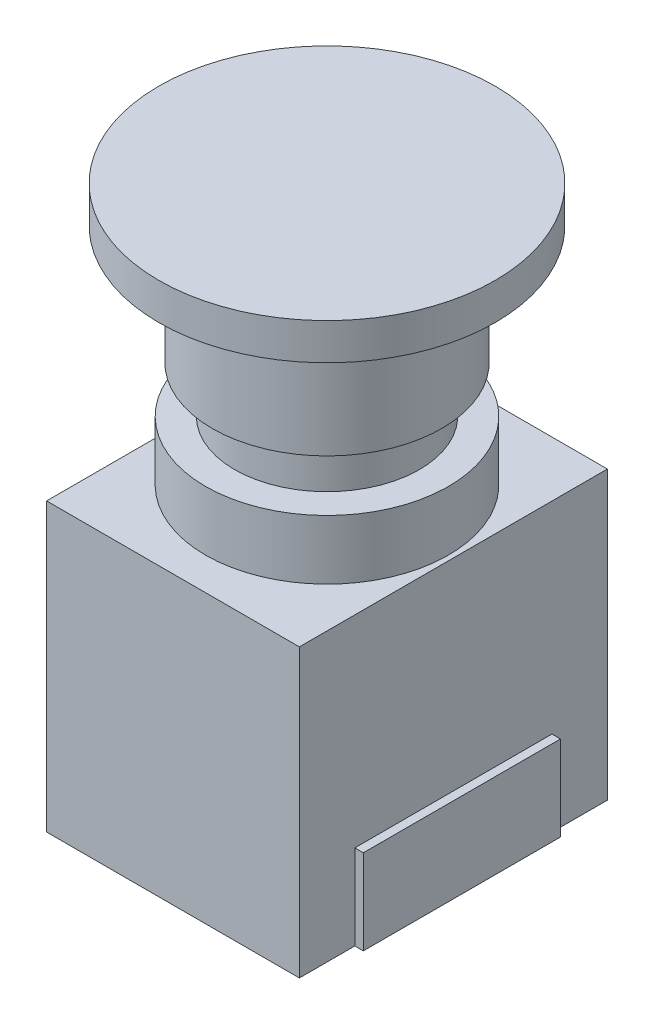
from build123d import *

# Parameters (mm, degrees)
SKETCH2_W           = 29.75
SKETCH2_H           = 36.25
BOSS_EXTRUDE1_DEPTH = 33.75
SKETCH3_R           = 14.3
BOSS_EXTRUDE2_DEPTH = 7
SKETCH4_R           = 10.875
BOSS_EXTRUDE3_DEPTH = 5.5
SKETCH5_R           = 13.5
BOSS_EXTRUDE4_DEPTH = 13.95
SKETCH6_R           = 19.8
BOSS_EXTRUDE5_DEPTH = 4.3
SKETCH7_W           = 23.2
SKETCH7_H           = 10
BOSS_EXTRUDE6_DEPTH = 1


with BuildPart() as part:
    # Sketch2 → Boss-Extrude1 (new body)
    with BuildSketch(Plane(origin=(0, 0, 0), x_dir=(1, 0, 0), z_dir=(0, 1, 0))):
        Rectangle(SKETCH2_W, SKETCH2_H)
    extrude(amount=BOSS_EXTRUDE1_DEPTH)

    # Sketch3 → Boss-Extrude2 (add)
    with BuildSketch(Plane(origin=(0, 33.75, 0), x_dir=(1, 0, 0), z_dir=(0, 1, 0))):
        Circle(SKETCH3_R)
    extrude(amount=BOSS_EXTRUDE2_DEPTH)

    # Sketch4 → Boss-Extrude3 (add)
    with BuildSketch(Plane(origin=(0, 40.75, 0), x_dir=(1, 0, 0), z_dir=(0, 1, 0))):
        Circle(SKETCH4_R)
    extrude(amount=BOSS_EXTRUDE3_DEPTH)

    # Sketch5 → Boss-Extrude4 (add)
    with BuildSketch(Plane(origin=(0, 46.25, 0), x_dir=(1, 0, 0), z_dir=(0, 1, 0))):
        Circle(SKETCH5_R)
    extrude(amount=BOSS_EXTRUDE4_DEPTH)

    # Sketch6 → Boss-Extrude5 (add)
    with BuildSketch(Plane(origin=(0, 60.2, 0), x_dir=(1, 0, 0), z_dir=(0, 1, 0))):
        Circle(SKETCH6_R)
    extrude(amount=BOSS_EXTRUDE5_DEPTH)

    # Sketch7 → Boss-Extrude6 (add)
    with BuildSketch(Plane(origin=(14.875, 0, 0), x_dir=(0, 0, -1), z_dir=(1, 0, 0))):
        with Locations((0, 5)):
            Rectangle(SKETCH7_W, SKETCH7_H)
    extrude(amount=BOSS_EXTRUDE6_DEPTH)


solid = part.part
